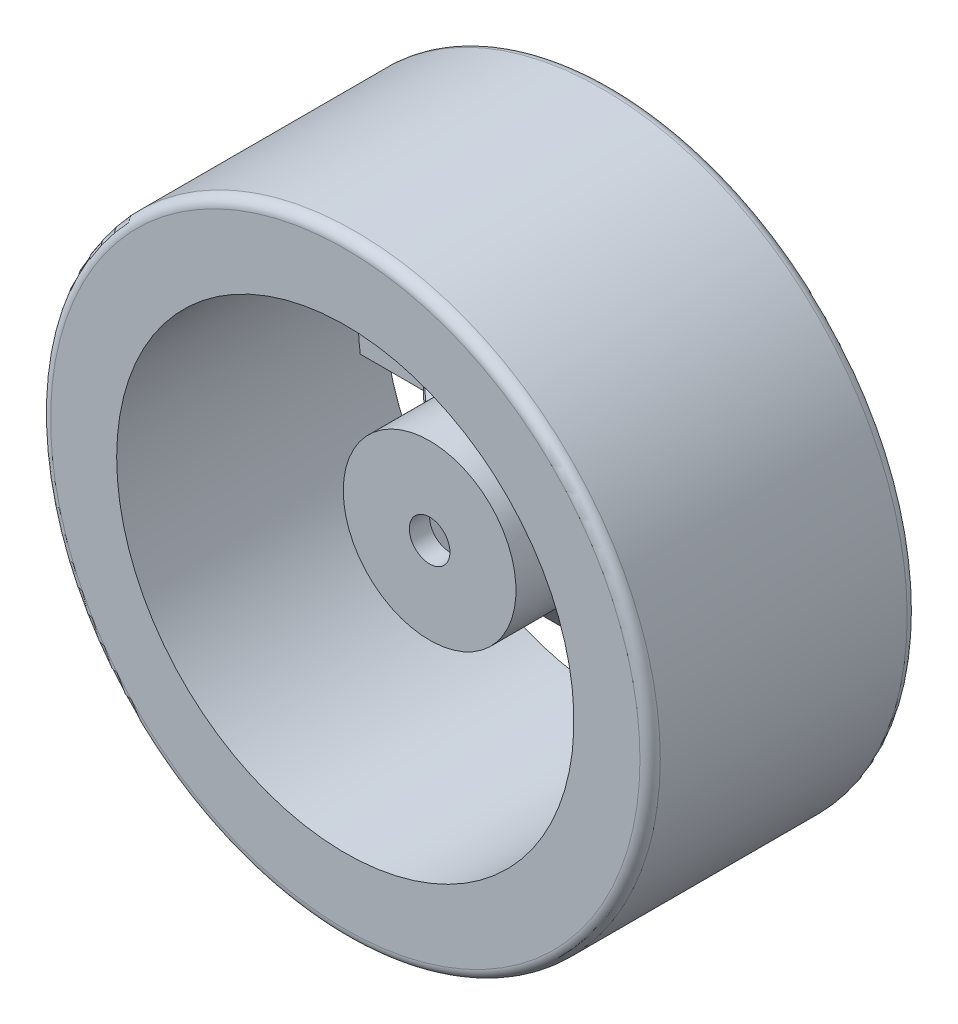
from build123d import *

# Parameters (mm, degrees)
SKETCH_1_R               = 30
EXTRUDE_1_DEPTH          = 26.3
SKETCH_2_R               = 22.5
CUT_EXTRUDE_1_DEPTH      = 27.3
SKETCH_3_R               = 8.5
SKETCH_3_R_2             = 2
EXTRUDE_2_DEPTH          = 8
CUT_EXTRUDE_2_DEPTH      = 6
EXTRUDE_3_DEPTH          = 3
PATTERN_CIRCULAR_1_COUNT = 7
FILLET_1_R               = 1


with BuildPart() as part:
    # 草图1 → 凸台-拉伸1 (new body)
    with BuildSketch(Plane.XY):
        Circle(SKETCH_1_R)
    extrude(amount=EXTRUDE_1_DEPTH)

    # 草图2 → 切除-拉伸1 (cut, through all)
    with BuildSketch(Plane(origin=(0, 0, 0), x_dir=(-1, 0, 0), z_dir=(0, 0, -1))):
        Circle(SKETCH_2_R)
    extrude(amount=-CUT_EXTRUDE_1_DEPTH, mode=Mode.SUBTRACT)



with BuildPart() as body_2:
    # 草图3 → 凸台-拉伸2 (new body)
    with BuildSketch(Plane(origin=(0, 0, 10), x_dir=(-1, 0, 0), z_dir=(0, 0, -1))):
        Circle(SKETCH_3_R)
        Circle(SKETCH_3_R_2, mode=Mode.SUBTRACT)
    extrude(amount=-EXTRUDE_2_DEPTH)

    # 草图4 → 切除-拉伸2 (cut)
    with BuildSketch(Plane(origin=(0, 0, 10), x_dir=(-1, 0, 0), z_dir=(0, 0, -1))):
        Polygon((7.216878365, 0), (3.608439182, 6.25), (-3.608439182, 6.25), (-7.216878365, 0), (-3.608439182, -6.25), (3.608439182, -6.25), align=None)
    extrude(amount=-CUT_EXTRUDE_2_DEPTH, mode=Mode.SUBTRACT)


with BuildPart() as part_1:
    add(part.part)

    add(body_2.part)  # 凸台-拉伸3 merges body 2
    # 草图5 → 凸台-拉伸3 (add, symmetric)
    with BuildSketch(Plane(origin=(0, 0, 0), x_dir=(1, 0, 0), z_dir=(0, 1, 0))):
        Polygon((-22.5, 0), (-15.275057212, 0), (-7.243077648, -10), (-8.396842229, -10), (-16.069885632, -2.529070305), (-24.164958171, -2.529070305), (-24.164958171, 0), align=None)
    extrude_3 = extrude(amount=EXTRUDE_3_DEPTH, both=True)

    # 阵列(圆周)1: 凸台-拉伸3 ×7 about axis
    pattern_circular_1_axis = Axis((0, 0, 0), (0, 0, 1))
    for i in range(1, PATTERN_CIRCULAR_1_COUNT):
        add(extrude_3.rotate(pattern_circular_1_axis, i * 360 / PATTERN_CIRCULAR_1_COUNT))

    # 圆角1
    fillet_1_edges = [part_1.edges().sort_by_distance(p)[0] for p in [
        (-30, 0, 0),
        (-30, 0, 26.3),
    ]]
    fillet(fillet_1_edges, radius=FILLET_1_R)


solid = part_1.part
